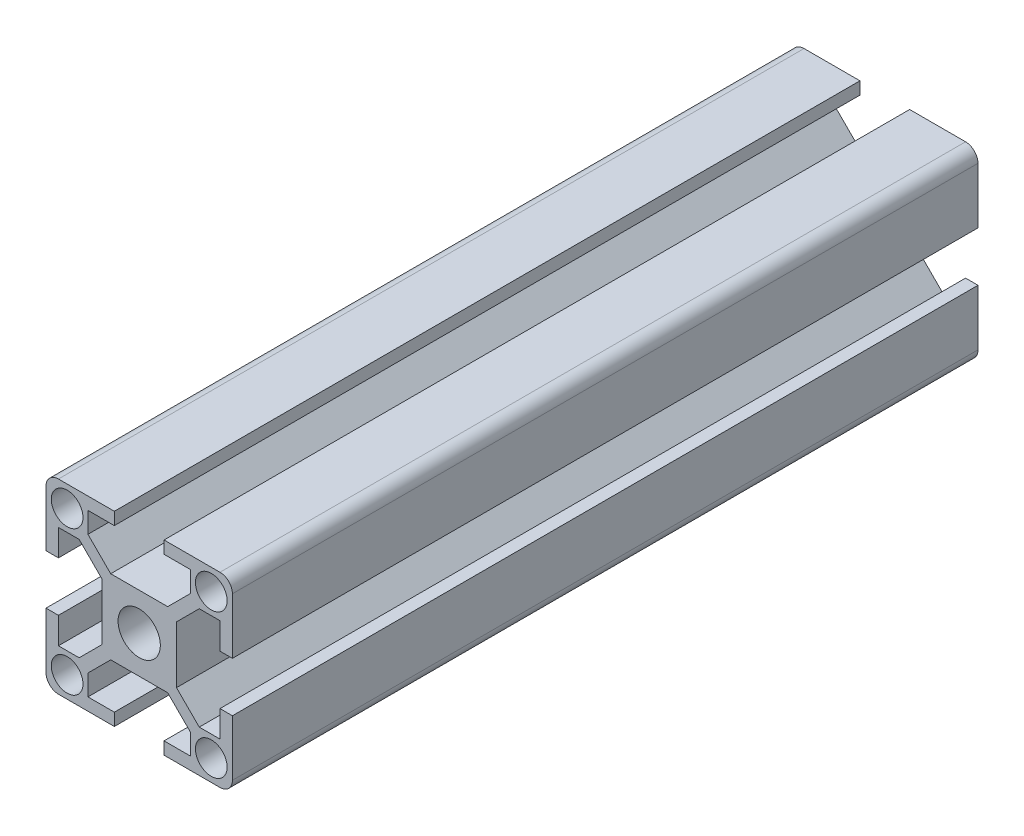
from build123d import *

# Parameters (mm, degrees)
SKETCH1_R           = 2.55
SKETCH1_R_2         = 3.4
BOSS_EXTRUDE1_DEPTH = 120


with BuildPart() as part:
    # Sketch1 → Boss-Extrude1 (new body)
    with BuildSketch(Plane.XY):
        with BuildLine():
            Line((-13, -15), (-4, -15))
            Line((-4, -15), (-4, -13))
            Line((-4, -13), (-8.25, -13))
            Line((-8.25, -13), (-8.25, -9.664213562))
            Line((-8.25, -9.664213562), (-4.585786438, -6))
            Line((-4.585786438, -6), (4.585786438, -6))
            Line((4.585786438, -6), (8.25, -9.664213562))
            Line((8.25, -9.664213562), (8.25, -13))
            Line((8.25, -13), (4, -13))
            Line((4, -13), (4, -15))
            Line((4, -15), (13, -15))
            ThreePointArc((13, -15), (14.414213562, -14.414213562), (15, -13))
            Line((15, -13), (15, -4))
            Line((15, -4), (13, -4))
            Line((13, -4), (13, -8.25))
            Line((13, -8.25), (9.664213562, -8.25))
            Line((9.664213562, -8.25), (6, -4.585786438))
            Line((6, -4.585786438), (6, 4.585786438))
            Line((6, 4.585786438), (9.664213562, 8.25))
            Line((9.664213562, 8.25), (13, 8.25))
            Line((13, 8.25), (13, 4))
            Line((13, 4), (15, 4))
            Line((15, 4), (15, 13))
            ThreePointArc((15, 13), (14.414213562, 14.414213562), (13, 15))
            Line((13, 15), (4, 15))
            Line((4, 15), (4, 13))
            Line((4, 13), (8.25, 13))
            Line((8.25, 13), (8.25, 9.664213562))
            Line((8.25, 9.664213562), (4.585786438, 6))
            Line((4.585786438, 6), (-4.585786438, 6))
            Line((-4.585786438, 6), (-8.25, 9.664213562))
            Line((-8.25, 9.664213562), (-8.25, 13))
            Line((-8.25, 13), (-4, 13))
            Line((-4, 13), (-4, 15))
            Line((-4, 15), (-13, 15))
            ThreePointArc((-13, 15), (-14.414213562, 14.414213562), (-15, 13))
            Line((-15, 13), (-15, 4))
            Line((-15, 4), (-13, 4))
            Line((-13, 4), (-13, 8.25))
            Line((-13, 8.25), (-9.664213562, 8.25))
            Line((-9.664213562, 8.25), (-6, 4.585786438))
            Line((-6, 4.585786438), (-6, -4.585786438))
            Line((-6, -4.585786438), (-9.664213562, -8.25))
            Line((-9.664213562, -8.25), (-13, -8.25))
            Line((-13, -8.25), (-13, -4))
            Line((-13, -4), (-15, -4))
            Line((-15, -4), (-15, -13))
            ThreePointArc((-15, -13), (-14.414213562, -14.414213562), (-13, -15))
        make_face()
        with Locations(Location((-11.6, 11.6, 0), (0, 0, 180))):  # turned: the seam where the file's is
            Circle(SKETCH1_R, mode=Mode.SUBTRACT)
        with Locations(Location((0, 0, 0), (0, 0, 180))):  # turned: the seam where the file's is
            Circle(SKETCH1_R_2, mode=Mode.SUBTRACT)
        with Locations(Location((-11.6, -11.6, 0), (0, 0, 180))):  # turned: the seam where the file's is
            Circle(SKETCH1_R, mode=Mode.SUBTRACT)
        with Locations(Location((11.6, -11.6, 0), (0, 0, 180))):  # turned: the seam where the file's is
            Circle(SKETCH1_R, mode=Mode.SUBTRACT)
        with Locations(Location((11.6, 11.6, 0), (0, 0, 180))):  # turned: the seam where the file's is
            Circle(SKETCH1_R, mode=Mode.SUBTRACT)
    extrude(amount=BOSS_EXTRUDE1_DEPTH)


solid = part.part
